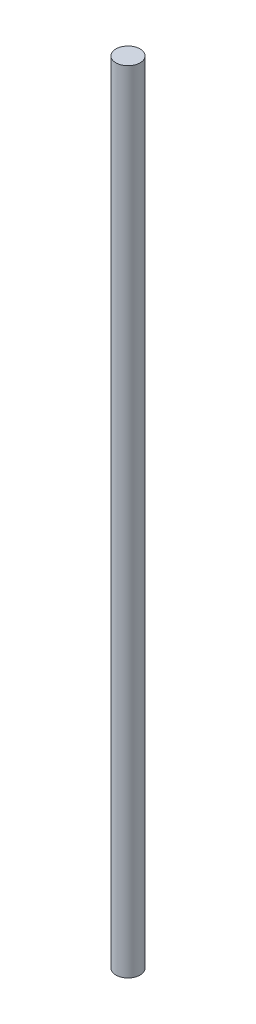
from build123d import *

# Parameters (mm, degrees)
SKETCH1_R           = 10
BOSS_EXTRUDE1_DEPTH = 654


with BuildPart() as part:
    # Sketch1 → Boss-Extrude1 (new body)
    with BuildSketch(Plane(origin=(0, 0, 0), x_dir=(1, 0, 0), z_dir=(0, 1, 0))):
        Circle(SKETCH1_R)
    extrude(amount=BOSS_EXTRUDE1_DEPTH)


solid = part.part
